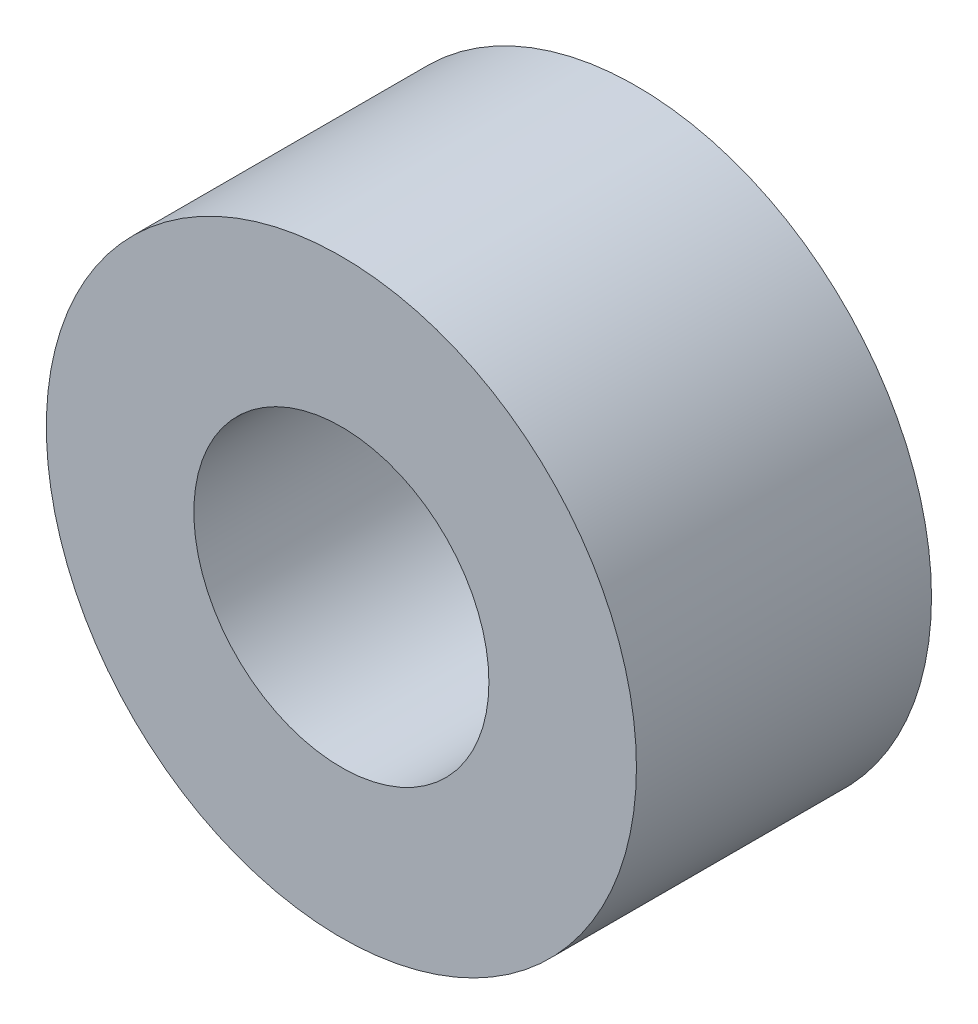
from build123d import *

# Parameters (mm, degrees)
SKETCH1_R      = 3.175
SKETCH1_R_2    = 1.5875
EXTRUDE1_DEPTH = 1.5875


with BuildPart() as part:
    # Sketch1 → Extrude1 (new body, symmetric)
    with BuildSketch(Plane.XY):
        Circle(SKETCH1_R)
        Circle(SKETCH1_R_2, mode=Mode.SUBTRACT)
    extrude(amount=EXTRUDE1_DEPTH, both=True)


solid = part.part
